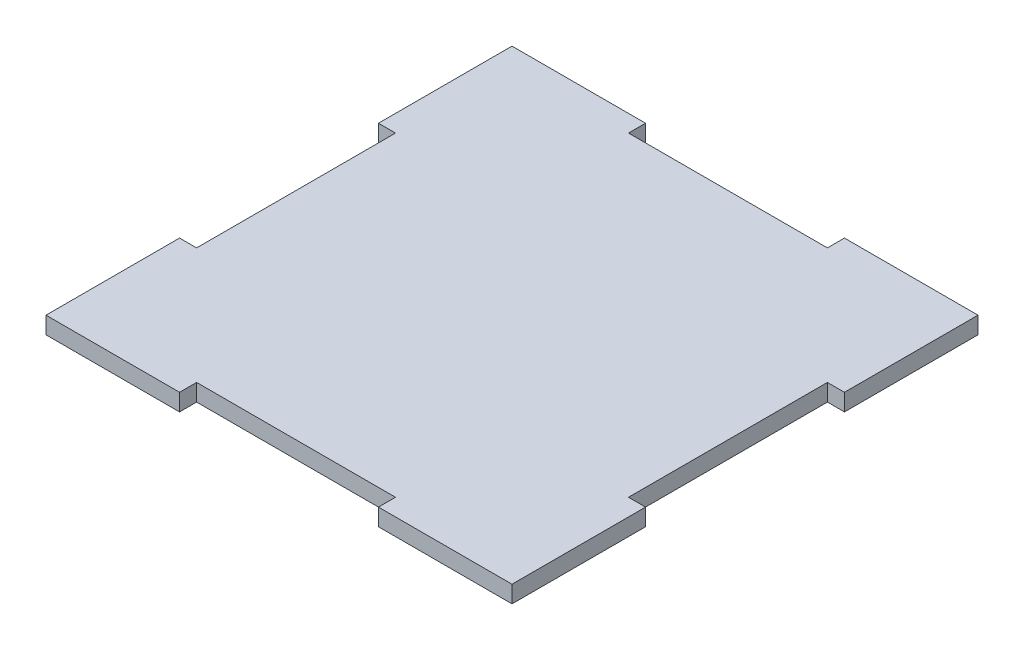
from build123d import *

# Parameters (mm, degrees)
BOSS_EXTRUDE1_DEPTH = 3


with BuildPart() as part:
    # Sketch1 → Boss-Extrude1 (new body)
    with BuildSketch(Plane(origin=(0, 0, 0), x_dir=(1, 0, 0), z_dir=(0, 1, 0))):
        Polygon((-41, -41), (-17.5, -41), (-17.5, -38), (17.5, -38), (17.5, -41), (41, -41), (41, -17.5), (38, -17.5), (38, 17.5), (41, 17.5), (41, 41), (17.5, 41), (17.5, 38), (-17.5, 38), (-17.5, 41), (-41, 41), (-41, 17.5), (-38, 17.5), (-38, -17.5), (-41, -17.5), align=None)
    extrude(amount=BOSS_EXTRUDE1_DEPTH)


solid = part.part
